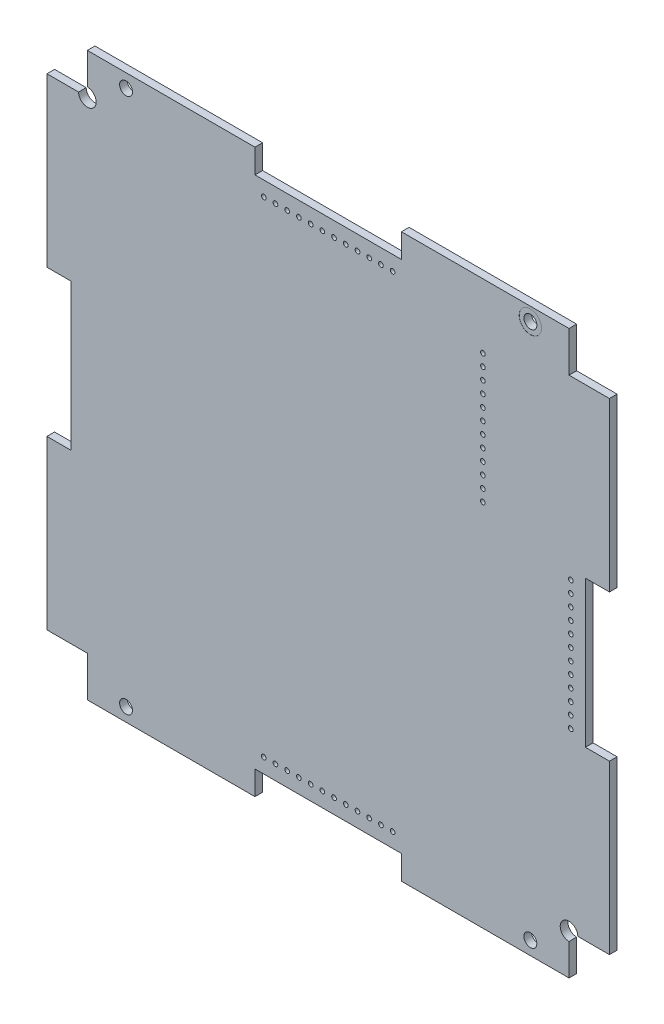
from build123d import *

# Parameters (mm, degrees)
BOSS_EXTRUDE1_DEPTH            = 1.3
SKETCH2_W                      = 7
SKETCH2_H                      = 7
CUT_EXTRUDE1_DEPTH             = 8.5
F_2_2_2_2_DIAMETER_HOLE1_D     = 2.2
F_2_2_2_2_DIAMETER_HOLE1_DEPTH = 13
SKETCH18_R                     = 1.5
CUT_EXTRUDE2_DEPTH             = 2.3
SKETCH19_W                     = 0.1
SKETCH19_H                     = 82.2
SKETCH19_W_2                   = 82.2
SKETCH19_H_2                   = 0.1
CUT_EXTRUDE3_DEPTH             = 2.3
CUT_EXTRUDE4_REACH             = 3.3
SKETCH20_R                     = 0.4
SKETCH21_R                     = 0.4
CUT_EXTRUDE5_DEPTH             = 2.3
SKETCH22_R                     = 0.4
CUT_EXTRUDE6_DEPTH             = 2.3
SKETCH23_R                     = 0.4
CUT_EXTRUDE7_DEPTH             = 2.3
SKETCH_1_R                     = 1.9
CUT_EXTRUDE_1_DEPTH            = 0.01
SKETCH_2_R                     = 1.9
CUT_EXTRUDE_2_DEPTH            = 0.01


with BuildPart() as part:
    # Sketch1 → Boss-Extrude1 (new body)
    with BuildSketch(Plane.XY):
        Polygon((-48.1, 12.5), (-43.9, 12.5), (-43.9, -12.5), (-48.1, -12.5), (-48.1, -48.1), (-12.5, -48.1), (-12.5, -43.9), (12.5, -43.9), (12.5, -48.1), (48.1, -48.1), (48.1, -12.5), (43.9, -12.5), (43.9, 12.5), (48.1, 12.5), (48.1, 48.1), (12.5, 48.1), (12.5, 43.9), (-12.5, 43.9), (-12.5, 48.1), (-48.1, 48.1), align=None)
    extrude(amount=BOSS_EXTRUDE1_DEPTH)

    # Sketch2 → Cut-Extrude1 (cut)
    with BuildSketch(Plane.XY.offset(1.3)):
        with Locations((-44.6, 44.6)):
            Rectangle(SKETCH2_W, SKETCH2_H)
        with Locations((44.6, 44.6)):
            Rectangle(SKETCH2_W, SKETCH2_H)
        with Locations((44.6, -44.6)):
            Rectangle(SKETCH2_W, SKETCH2_H)
        with Locations((-44.6, -44.6)):
            Rectangle(SKETCH2_W, SKETCH2_H)
    extrude(amount=-CUT_EXTRUDE1_DEPTH, mode=Mode.SUBTRACT)

    # Ø2.2 (2.2) Diameter Hole1
    with Locations(Plane.XY.offset(1.3)):
        with Locations((-34.5, 45.7), (34.5, 45.7), (-34.5, -45.7), (34.5, -45.7)):
            Hole(F_2_2_2_2_DIAMETER_HOLE1_D / 2, depth=F_2_2_2_2_DIAMETER_HOLE1_DEPTH)

    # Sketch18 → Cut-Extrude2 (cut, through all)
    with BuildSketch(Plane(origin=(0, 0, 0), x_dir=(-1, 0, 0), z_dir=(0, 0, -1))):
        with Locations((41.1, 41.1)):
            Circle(SKETCH18_R)
        with Locations((-41.1, -41.1)):
            Circle(SKETCH18_R)
    extrude(amount=-CUT_EXTRUDE2_DEPTH, mode=Mode.SUBTRACT)

    # Sketch19 → Cut-Extrude3 (cut, through all)
    with BuildSketch(Plane(origin=(0, 0, 0), x_dir=(-1, 0, 0), z_dir=(0, 0, -1))):
        with Locations((48.05, 0)):
            Rectangle(SKETCH19_W, SKETCH19_H)
        with Locations((0, -48.05)):
            Rectangle(SKETCH19_W_2, SKETCH19_H_2)
        with Locations((-48.05, 0)):
            Rectangle(SKETCH19_W, SKETCH19_H)
        with Locations((0, 48.05)):
            Rectangle(SKETCH19_W_2, SKETCH19_H_2)
    extrude(amount=-CUT_EXTRUDE3_DEPTH, mode=Mode.SUBTRACT)

    # Sketch20 → Cut-Extrude4 (cut, up to next)
    with BuildSketch(Plane.XY.offset(1.3), mode=Mode.PRIVATE) as cut_extrude4_sk1:
        with Locations((26.4, 15)):
            Circle(SKETCH20_R)
    cut_extrude4_tool1 = extrude(cut_extrude4_sk1.sketch, amount=-CUT_EXTRUDE4_REACH, mode=Mode.PRIVATE) & part.part
    add(cut_extrude4_tool1.solids().sort_by_distance((26.4, 15, 1.3))[0], mode=Mode.SUBTRACT)
    # Sketch20 → Cut-Extrude4 (cut, up to next)
    with BuildSketch(Plane.XY.offset(1.3), mode=Mode.PRIVATE) as cut_extrude4_sk2:
        with Locations((26.4, 17)):
            Circle(SKETCH20_R)
    cut_extrude4_tool2 = extrude(cut_extrude4_sk2.sketch, amount=-CUT_EXTRUDE4_REACH, mode=Mode.PRIVATE) & part.part
    add(cut_extrude4_tool2.solids().sort_by_distance((26.4, 17, 1.3))[0], mode=Mode.SUBTRACT)
    # Sketch20 → Cut-Extrude4 (cut, up to next)
    with BuildSketch(Plane.XY.offset(1.3), mode=Mode.PRIVATE) as cut_extrude4_sk3:
        with Locations((26.4, 19)):
            Circle(SKETCH20_R)
    cut_extrude4_tool3 = extrude(cut_extrude4_sk3.sketch, amount=-CUT_EXTRUDE4_REACH, mode=Mode.PRIVATE) & part.part
    add(cut_extrude4_tool3.solids().sort_by_distance((26.4, 19, 1.3))[0], mode=Mode.SUBTRACT)
    # Sketch20 → Cut-Extrude4 (cut, up to next)
    with BuildSketch(Plane.XY.offset(1.3), mode=Mode.PRIVATE) as cut_extrude4_sk4:
        with Locations((26.4, 21)):
            Circle(SKETCH20_R)
    cut_extrude4_tool4 = extrude(cut_extrude4_sk4.sketch, amount=-CUT_EXTRUDE4_REACH, mode=Mode.PRIVATE) & part.part
    add(cut_extrude4_tool4.solids().sort_by_distance((26.4, 21, 1.3))[0], mode=Mode.SUBTRACT)
    # Sketch20 → Cut-Extrude4 (cut, up to next)
    with BuildSketch(Plane.XY.offset(1.3), mode=Mode.PRIVATE) as cut_extrude4_sk5:
        with Locations((26.4, 23)):
            Circle(SKETCH20_R)
    cut_extrude4_tool5 = extrude(cut_extrude4_sk5.sketch, amount=-CUT_EXTRUDE4_REACH, mode=Mode.PRIVATE) & part.part
    add(cut_extrude4_tool5.solids().sort_by_distance((26.4, 23, 1.3))[0], mode=Mode.SUBTRACT)
    # Sketch20 → Cut-Extrude4 (cut, up to next)
    with BuildSketch(Plane.XY.offset(1.3), mode=Mode.PRIVATE) as cut_extrude4_sk6:
        with Locations((26.4, 25)):
            Circle(SKETCH20_R)
    cut_extrude4_tool6 = extrude(cut_extrude4_sk6.sketch, amount=-CUT_EXTRUDE4_REACH, mode=Mode.PRIVATE) & part.part
    add(cut_extrude4_tool6.solids().sort_by_distance((26.4, 25, 1.3))[0], mode=Mode.SUBTRACT)
    # Sketch20 → Cut-Extrude4 (cut, up to next)
    with BuildSketch(Plane.XY.offset(1.3), mode=Mode.PRIVATE) as cut_extrude4_sk7:
        with Locations((26.4, 27)):
            Circle(SKETCH20_R)
    cut_extrude4_tool7 = extrude(cut_extrude4_sk7.sketch, amount=-CUT_EXTRUDE4_REACH, mode=Mode.PRIVATE) & part.part
    add(cut_extrude4_tool7.solids().sort_by_distance((26.4, 27, 1.3))[0], mode=Mode.SUBTRACT)
    # Sketch20 → Cut-Extrude4 (cut, up to next)
    with BuildSketch(Plane.XY.offset(1.3), mode=Mode.PRIVATE) as cut_extrude4_sk8:
        with Locations((26.4, 29)):
            Circle(SKETCH20_R)
    cut_extrude4_tool8 = extrude(cut_extrude4_sk8.sketch, amount=-CUT_EXTRUDE4_REACH, mode=Mode.PRIVATE) & part.part
    add(cut_extrude4_tool8.solids().sort_by_distance((26.4, 29, 1.3))[0], mode=Mode.SUBTRACT)
    # Sketch20 → Cut-Extrude4 (cut, up to next)
    with BuildSketch(Plane.XY.offset(1.3), mode=Mode.PRIVATE) as cut_extrude4_sk9:
        with Locations((26.4, 31)):
            Circle(SKETCH20_R)
    cut_extrude4_tool9 = extrude(cut_extrude4_sk9.sketch, amount=-CUT_EXTRUDE4_REACH, mode=Mode.PRIVATE) & part.part
    add(cut_extrude4_tool9.solids().sort_by_distance((26.4, 31, 1.3))[0], mode=Mode.SUBTRACT)
    # Sketch20 → Cut-Extrude4 (cut, up to next)
    with BuildSketch(Plane.XY.offset(1.3), mode=Mode.PRIVATE) as cut_extrude4_sk10:
        with Locations((26.4, 33)):
            Circle(SKETCH20_R)
    cut_extrude4_tool10 = extrude(cut_extrude4_sk10.sketch, amount=-CUT_EXTRUDE4_REACH, mode=Mode.PRIVATE) & part.part
    add(cut_extrude4_tool10.solids().sort_by_distance((26.4, 33, 1.3))[0], mode=Mode.SUBTRACT)
    # Sketch20 → Cut-Extrude4 (cut, up to next)
    with BuildSketch(Plane.XY.offset(1.3), mode=Mode.PRIVATE) as cut_extrude4_sk11:
        with Locations((26.4, 35)):
            Circle(SKETCH20_R)
    cut_extrude4_tool11 = extrude(cut_extrude4_sk11.sketch, amount=-CUT_EXTRUDE4_REACH, mode=Mode.PRIVATE) & part.part
    add(cut_extrude4_tool11.solids().sort_by_distance((26.4, 35, 1.3))[0], mode=Mode.SUBTRACT)
    # Sketch20 → Cut-Extrude4 (cut, up to next)
    with BuildSketch(Plane.XY.offset(1.3), mode=Mode.PRIVATE) as cut_extrude4_sk12:
        with Locations((26.4, 37)):
            Circle(SKETCH20_R)
    cut_extrude4_tool12 = extrude(cut_extrude4_sk12.sketch, amount=-CUT_EXTRUDE4_REACH, mode=Mode.PRIVATE) & part.part
    add(cut_extrude4_tool12.solids().sort_by_distance((26.4, 37, 1.3))[0], mode=Mode.SUBTRACT)

    # Sketch21 → Cut-Extrude5 (cut, through all)
    with BuildSketch(Plane.XY.offset(1.3)):
        with Locations((11, 41.4)):
            Circle(SKETCH21_R)
        with Locations((9, 41.4)):
            Circle(SKETCH21_R)
        with Locations((7, 41.4)):
            Circle(SKETCH21_R)
        with Locations((5, 41.4)):
            Circle(SKETCH21_R)
        with Locations((3, 41.4)):
            Circle(SKETCH21_R)
        with Locations((1, 41.4)):
            Circle(SKETCH21_R)
        with Locations((-1, 41.4)):
            Circle(SKETCH21_R)
        with Locations((-3, 41.4)):
            Circle(SKETCH21_R)
        with Locations((-5, 41.4)):
            Circle(SKETCH21_R)
        with Locations((-7, 41.4)):
            Circle(SKETCH21_R)
        with Locations((-9, 41.4)):
            Circle(SKETCH21_R)
        with Locations((-11, 41.4)):
            Circle(SKETCH21_R)
    extrude(amount=-CUT_EXTRUDE5_DEPTH, mode=Mode.SUBTRACT)

    # Sketch22 → Cut-Extrude6 (cut, through all)
    with BuildSketch(Plane.XY.offset(1.3)):
        with Locations((41.4, 11)):
            Circle(SKETCH22_R)
        with Locations((41.4, 9)):
            Circle(SKETCH22_R)
        with Locations((41.4, 7)):
            Circle(SKETCH22_R)
        with Locations((41.4, 5)):
            Circle(SKETCH22_R)
        with Locations((41.4, 3)):
            Circle(SKETCH22_R)
        with Locations((41.4, 1)):
            Circle(SKETCH22_R)
        with Locations((41.4, -1)):
            Circle(SKETCH22_R)
        with Locations((41.4, -3)):
            Circle(SKETCH22_R)
        with Locations((41.4, -5)):
            Circle(SKETCH22_R)
        with Locations((41.4, -7)):
            Circle(SKETCH22_R)
        with Locations((41.4, -9)):
            Circle(SKETCH22_R)
        with Locations((41.4, -11)):
            Circle(SKETCH22_R)
    extrude(amount=-CUT_EXTRUDE6_DEPTH, mode=Mode.SUBTRACT)

    # Sketch23 → Cut-Extrude7 (cut, through all)
    with BuildSketch(Plane.XY.offset(1.3)):
        with Locations((11, -41.4)):
            Circle(SKETCH23_R)
        with Locations((9, -41.4)):
            Circle(SKETCH23_R)
        with Locations((7, -41.4)):
            Circle(SKETCH23_R)
        with Locations((5, -41.4)):
            Circle(SKETCH23_R)
        with Locations((3, -41.4)):
            Circle(SKETCH23_R)
        with Locations((1, -41.4)):
            Circle(SKETCH23_R)
        with Locations((-1, -41.4)):
            Circle(SKETCH23_R)
        with Locations((-3, -41.4)):
            Circle(SKETCH23_R)
        with Locations((-5, -41.4)):
            Circle(SKETCH23_R)
        with Locations((-7, -41.4)):
            Circle(SKETCH23_R)
        with Locations((-9, -41.4)):
            Circle(SKETCH23_R)
        with Locations((-11, -41.4)):
            Circle(SKETCH23_R)
    extrude(amount=-CUT_EXTRUDE7_DEPTH, mode=Mode.SUBTRACT)

    # ｽｹｯﾁ1 → ｶｯﾄ - 押し出し1 (cut)
    with BuildSketch(Plane.XY.offset(1.3)):
        with Locations((34.5, 45.7)):
            Circle(SKETCH_1_R)
    extrude(amount=-CUT_EXTRUDE_1_DEPTH, mode=Mode.SUBTRACT)

    # ｽｹｯﾁ2 → ｶｯﾄ - 押し出し2 (cut)
    with BuildSketch(Plane(origin=(0, 0, 0), x_dir=(-1, 0, 0), z_dir=(0, 0, -1))):
        with Locations((-34.5, 45.7)):
            Circle(SKETCH_2_R)
    extrude(amount=-CUT_EXTRUDE_2_DEPTH, mode=Mode.SUBTRACT)


solid = part.part
